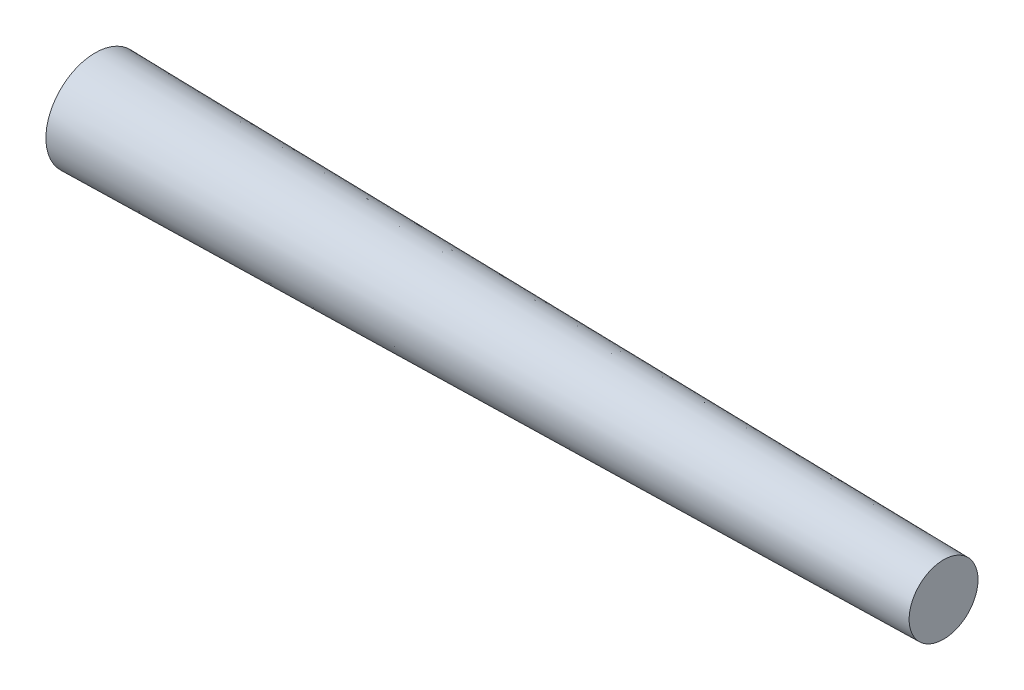
from build123d import *

# Parameters (mm, degrees)
SKETCH1_R           = 5.05
BOSS_EXTRUDE1_DEPTH = 87
BOSS_EXTRUDE1_TAPER = 1
SKETCH2_R           = 0.5
BOSS_EXTRUDE2_DEPTH = 0.5


with BuildPart() as part:
    # Sketch1 → Boss-Extrude1 (new body)
    with BuildSketch(Plane(origin=(0, 0, 0), x_dir=(0, 0, -1), z_dir=(1, 0, 0))):
        Circle(SKETCH1_R)
    extrude(amount=BOSS_EXTRUDE1_DEPTH, taper=BOSS_EXTRUDE1_TAPER)

    # Sketch2 → Boss-Extrude2 (add, symmetric)
    with BuildSketch(Plane(origin=(0, 0, 0), x_dir=(1, 0, 0), z_dir=(0, 1, 0))):
        with BuildLine():
            Line((0, 1), (-1, 1))
            ThreePointArc((-1, 1), (-2, 0), (-1, -1))
            Line((-1, -1), (0, -1))
            Line((0, -1), (0, 1))
        make_face()
        with Locations((-1, 0)):
            Circle(SKETCH2_R, mode=Mode.SUBTRACT)
    extrude(amount=BOSS_EXTRUDE2_DEPTH, both=True)


solid = part.part
